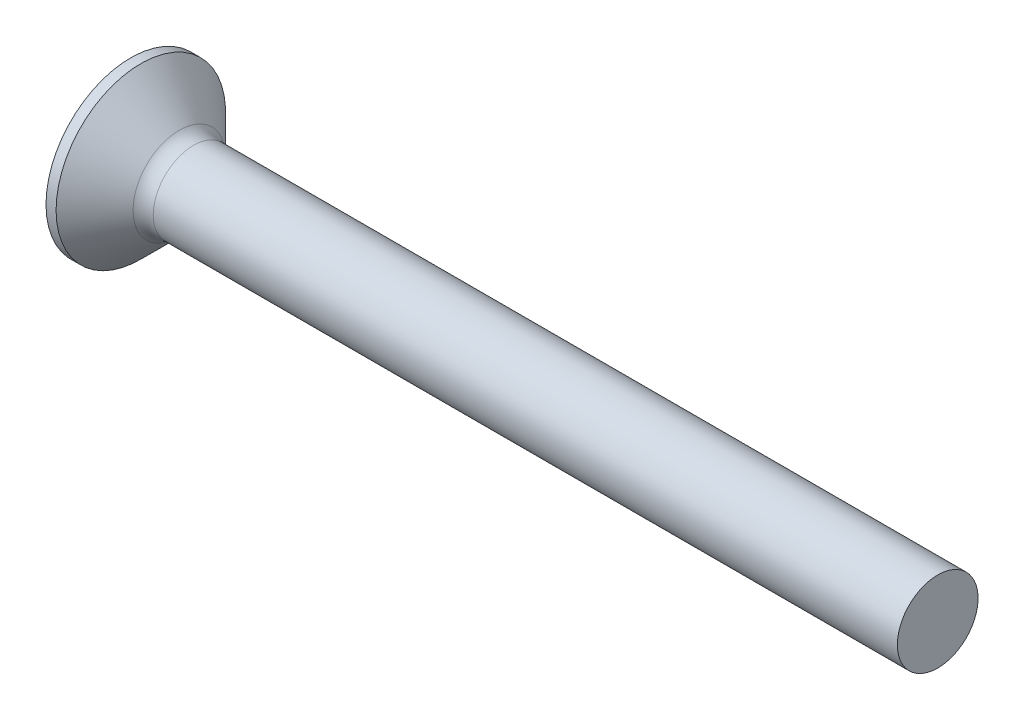
from build123d import *

# Parameters (mm, degrees)
FILLET1_R    = 1
SKETCH3_W    = 1.03
SKETCH3_H    = 4.4
SKETCH4_W    = 1.03
SKETCH4_H    = 1.897120414
RECPAT_COUNT = 2
RECPAT_ANGLE = 90


with BuildPart() as part:
    # BodySke → Base-Revolve (revolve)
    with BuildSketch(Plane.XY):
        Polygon((0, 0), (0, 4.2), (0.5, 4.2), (2.7, 2), (40, 2), (40, 0), align=None)
    revolve(axis=Axis((-6.35, 0, 0), (1, 0, 0)))

    # Fillet1
    fillet1_edges = [part.edges().sort_by_distance(p)[0] for p in [
        (2.7, -2, 0),
    ]]
    fillet(fillet1_edges, radius=FILLET1_R)

    # Sketch3 → Recess section 0
    with BuildSketch(Plane.ZY):
        Rectangle(SKETCH3_W, SKETCH3_H)
    # Sketch4 → Recess section 1
    with BuildSketch(Plane.ZY.offset(-2.51)):
        Rectangle(SKETCH4_W, SKETCH4_H)
    recess = loft(mode=Mode.SUBTRACT)

    # RecPat: Recess ×2 about axis
    recpat_axis = Axis((0, 0, 0), (1, 0, 0))
    for i in range(1, RECPAT_COUNT):
        add(recess.rotate(recpat_axis, i * RECPAT_ANGLE / (RECPAT_COUNT - 1)), mode=Mode.SUBTRACT)

    # RecCorSke → RecessCore (revolve, cut)
    with BuildSketch(Plane.XY):
        Polygon((0, 0), (0, 1.026516298), (2.51, 0.851), (2.786506661, 0), align=None)
    revolve(axis=Axis((-3.175, 0, 0), (1, 0, 0)), mode=Mode.SUBTRACT)


solid = part.part
